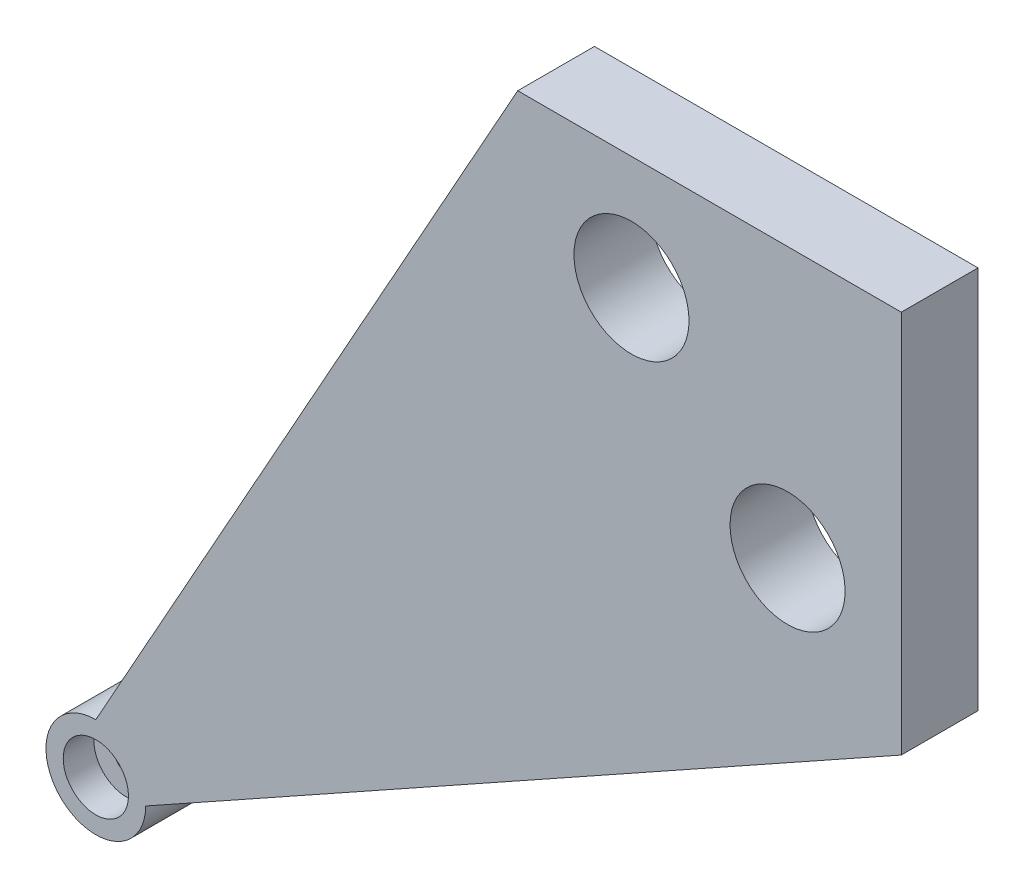
from build123d import *

# Parameters (mm, degrees)
RESSALTO_EXTRUS_O2_DEPTH = 5
ESBO_O4_R                = 4.25
CORTE_EXTRUS_O1_DEPTH    = 4
ESBO_O5_R                = 1.5
CORTE_EXTRUS_O2_DEPTH    = 7
ESBO_O6_R                = 7.5
CORTE_EXTRUS_O3_DEPTH    = 11


with BuildPart() as part:
    # Esboço3 → Ressalto-extrusão2 (new body, symmetric)
    with BuildSketch(Plane.XY):
        with BuildLine():
            Line((0, 50), (98.5, 105))
            ThreePointArc((98.5, 105), (109.596194078, 109.596194078), (105, 98.5))
            Line((105, 98.5), (50, 0))
            Line((50, 0), (0, 0))
            Line((0, 0), (0, 50))
        make_face()
    extrude(amount=RESSALTO_EXTRUS_O2_DEPTH, both=True)

    # Esboço4 → Corte-extrusão1 (cut)
    with BuildSketch(Plane.XY.offset(5)):
        with Locations((105, 105)):
            Circle(ESBO_O4_R)
    extrude(amount=-CORTE_EXTRUS_O1_DEPTH, mode=Mode.SUBTRACT)

    # Esboço5 → Corte-extrusão2 (cut, through all)
    with BuildSketch(Plane.XY.offset(1)):
        with Locations((105, 105)):
            Circle(ESBO_O5_R)
    extrude(amount=-CORTE_EXTRUS_O2_DEPTH, mode=Mode.SUBTRACT)

    # Esboço6 → Corte-extrusão3 (cut, through all)
    with BuildSketch(Plane.XY.offset(5)):
        with Locations((14.825558834, 35.174441166)):
            Circle(ESBO_O6_R)
        with Locations((35.174441166, 14.825558834)):
            Circle(ESBO_O6_R)
    extrude(amount=-CORTE_EXTRUS_O3_DEPTH, mode=Mode.SUBTRACT)


with BuildPart() as body_2:
    # Espelhar1: mirrored copy
    add(part.part.mirror(Plane(origin=(0, 0, 5), x_dir=(0, 0, 1), z_dir=(0, 1, 0))))


with BuildPart() as body_3:
    # Espelhar2: mirrored copy
    add(body_2.part.mirror(Plane(origin=(0, 0, 5), x_dir=(0, 0, 1), z_dir=(1, 0, 0))))


with BuildPart() as body_4:
    # Espelhar2 2: mirrored copy
    add(part.part.mirror(Plane(origin=(0, 0, 5), x_dir=(0, 0, 1), z_dir=(1, 0, 0))))


solid = body_3.part
